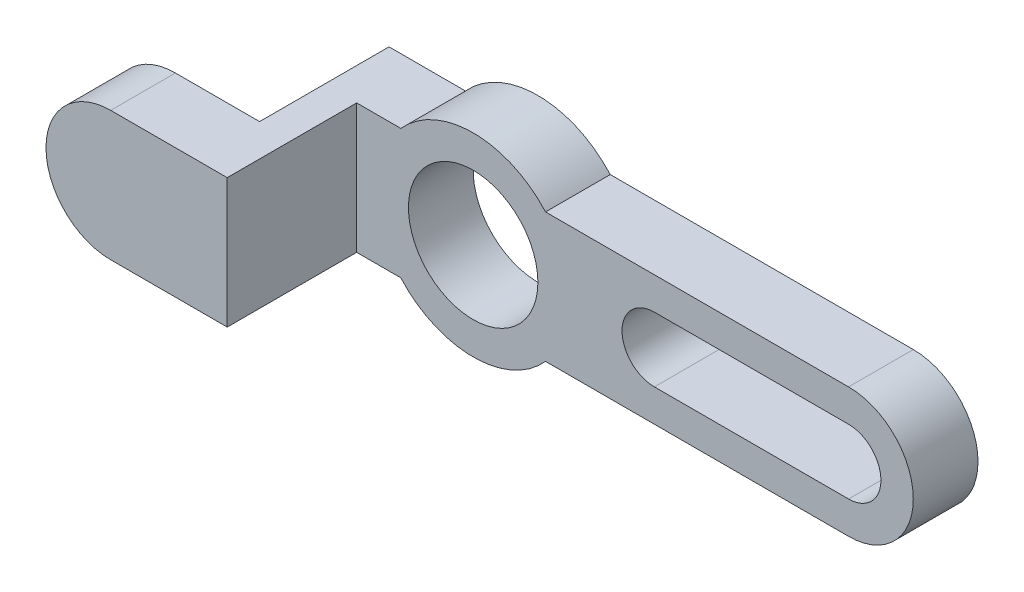
from build123d import *

# Parameters (mm, degrees)
SKETCH1_R           = 6.35
BOSS_EXTRUDE1_DEPTH = 3.175
SKETCH2_R           = 6.35
SKETCH2_R_2         = 3.175
BOSS_EXTRUDE2_DEPTH = 6.35
CUT_EXTRUDE2_DEPTH  = 6.35
SKETCH5_W           = 6.35
SKETCH5_H           = 12.7
BOSS_EXTRUDE3_DEPTH = 12.7
SKETCH6_W           = 6.35
SKETCH6_H           = 12.7
BOSS_EXTRUDE4_DEPTH = 5.08
SKETCH7_R           = 6.35
BOSS_EXTRUDE5_DEPTH = 6.35
SKETCH9_W           = 12.7
SKETCH9_H           = 12.7
CUT_EXTRUDE4_DEPTH  = 3.175


with BuildPart() as part:
    # Sketch1 → Boss-Extrude1 (new body, symmetric)
    with BuildSketch(Plane.XY):
        with BuildLine():
            Line((7.099515829, 6.35), (31.75, 6.35))
            Line((31.75, 6.35), (36.83, 6.35))
            Line((36.83, 6.35), (36.83, -6.35))
            Line((36.83, -6.35), (31.75, -6.35))
            Line((31.75, -6.35), (7.099515829, -6.35))
            ThreePointArc((7.099515829, -6.35), (0, -9.525), (-7.099515829, -6.35))
            Line((-7.099515829, -6.35), (-17.78, -6.35))
            Line((-17.78, -6.35), (-17.78, 6.35))
            Line((-17.78, 6.35), (-7.099515829, 6.35))
            ThreePointArc((-7.099515829, 6.35), (0, 9.525), (7.099515829, 6.35))
        make_face()
        Circle(SKETCH1_R, mode=Mode.SUBTRACT)
    extrude(amount=BOSS_EXTRUDE1_DEPTH, both=True)

    # Sketch2 → Boss-Extrude2 (add)
    with BuildSketch(Plane(origin=(0, 0, -3.175), x_dir=(-1, 0, 0), z_dir=(0, 0, -1))):
        with Locations((-36.83, 0)):
            Circle(SKETCH2_R)
        with Locations((-36.83, 0)):
            Circle(SKETCH2_R_2, mode=Mode.SUBTRACT)
    extrude(amount=-BOSS_EXTRUDE2_DEPTH)

    # Sketch4 → Cut-Extrude2 (cut)
    with BuildSketch(Plane.XY.offset(3.175)):
        with BuildLine():
            Line((36.83, 3.175), (17.78, 3.175))
            ThreePointArc((17.78, 3.175), (14.605, 0), (17.78, -3.175))
            Line((17.78, -3.175), (36.83, -3.175))
            ThreePointArc((36.83, -3.175), (40.005, 0), (36.83, 3.175))
        make_face()
    extrude(amount=-CUT_EXTRUDE2_DEPTH, mode=Mode.SUBTRACT)

    # Sketch5 → Boss-Extrude3 (add)
    with BuildSketch(Plane.XY.offset(3.175)):
        with Locations((-14.605, 0)):
            Rectangle(SKETCH5_W, SKETCH5_H)
    extrude(amount=BOSS_EXTRUDE3_DEPTH)

    # Sketch6 → Boss-Extrude4 (add)
    with BuildSketch(Plane.ZY.offset(17.78)):
        with Locations((12.7, 0)):
            Rectangle(SKETCH6_W, SKETCH6_H)
    extrude(amount=BOSS_EXTRUDE4_DEPTH)

    # Sketch7 → Boss-Extrude5 (add)
    with BuildSketch(Plane.XY.offset(15.875)):
        with Locations((-22.86, 0)):
            Circle(SKETCH7_R)
    extrude(amount=-BOSS_EXTRUDE5_DEPTH)

    # Sketch9 → Cut-Extrude4 (cut)
    with BuildSketch(Plane.ZY.offset(17.78)):
        with Locations((3.175, 0)):
            Rectangle(SKETCH9_W, SKETCH9_H)
    extrude(amount=-CUT_EXTRUDE4_DEPTH, mode=Mode.SUBTRACT)


solid = part.part
